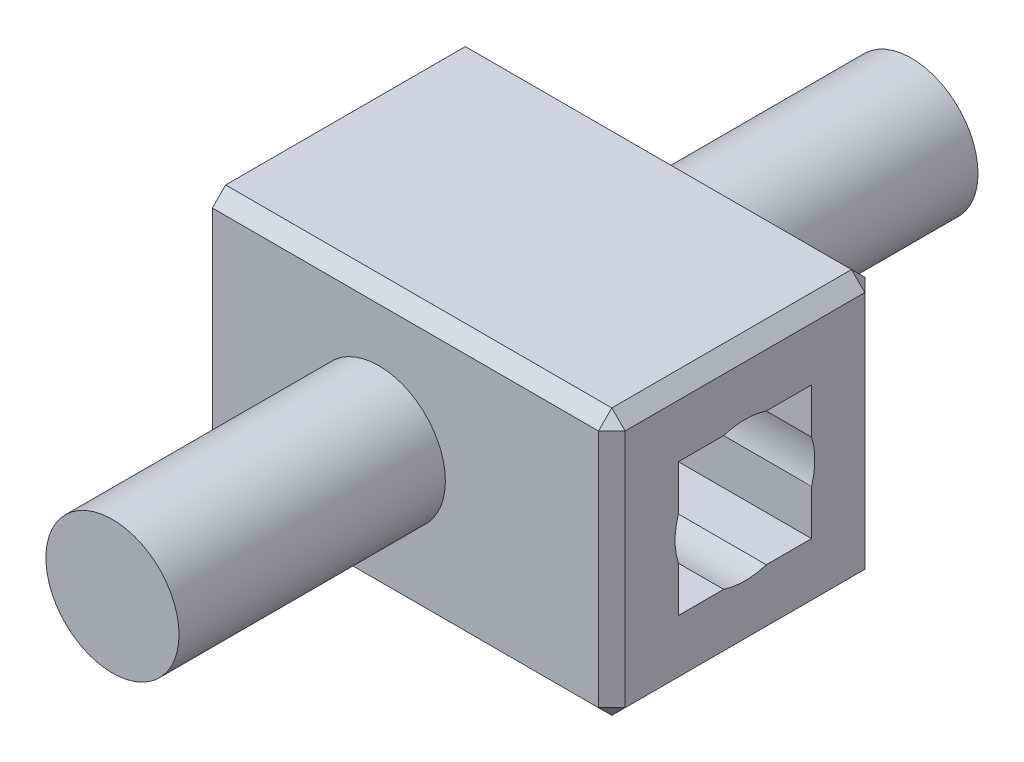
from build123d import *

# Parameters (mm, degrees)
SALIENTE_EXTRUIR1_DEPTH      = 200
CROQUIS2_R                   = 50
SALIENTE_EXTRUIR2_DEPTH      = 200
SALIENTE_EXTRUIR2_DEPTH_BACK = 400
CROQUIS3_W                   = 100
CROQUIS3_H                   = 100
CORTAR_EXTRUIR1_DEPTH        = 301
CROQUIS4_R                   = 52.5
CORTAR_EXTRUIR2_DEPTH        = 301
CHAFL_N1_SIZE                = 10


with BuildPart() as part:
    # Croquis1 → Saliente-Extruir1 (new body)
    with BuildSketch(Plane.XY):
        Polygon((-125, 100), (125, 100), (175, 100), (175, -100), (125, -100), (-125, -100), align=None)
    extrude(amount=SALIENTE_EXTRUIR1_DEPTH)

    # Croquis2 → Saliente-Extruir2 (add, two sides)
    with BuildSketch(Plane.XY.offset(200)) as saliente_extruir2_sk:
        Circle(CROQUIS2_R)
    extrude(amount=SALIENTE_EXTRUIR2_DEPTH)
    extrude(saliente_extruir2_sk.sketch, amount=-SALIENTE_EXTRUIR2_DEPTH_BACK)

    # Croquis3 → Cortar-Extruir1 (cut, through all)
    with BuildSketch(Plane(origin=(175, 0, 0), x_dir=(0, 0, -1), z_dir=(1, 0, 0))):
        with Locations((-100, 0)):
            Rectangle(CROQUIS3_W, CROQUIS3_H)
    extrude(amount=-CORTAR_EXTRUIR1_DEPTH, mode=Mode.SUBTRACT)

    # Croquis4 → Cortar-Extruir2 (cut, through all)
    with BuildSketch(Plane(origin=(175, 0, 0), x_dir=(0, 0, -1), z_dir=(1, 0, 0))):
        with Locations((-100, 0)):
            Circle(CROQUIS4_R)
    extrude(amount=-CORTAR_EXTRUIR2_DEPTH, mode=Mode.SUBTRACT)

    # Chaflán1
    chafl_n1_edges = [part.edges().sort_by_distance(p)[0] for p in [
        (175, 100, 100),
        (175, -100, 100),
        (25, 100, 200),
        (25, -100, 200),
        (25, -100, 0),
        (25, 100, 0),
        (175, 0, 0),
        (175, 0, 200),
    ]]
    chamfer(chafl_n1_edges, length=CHAFL_N1_SIZE)


solid = part.part
